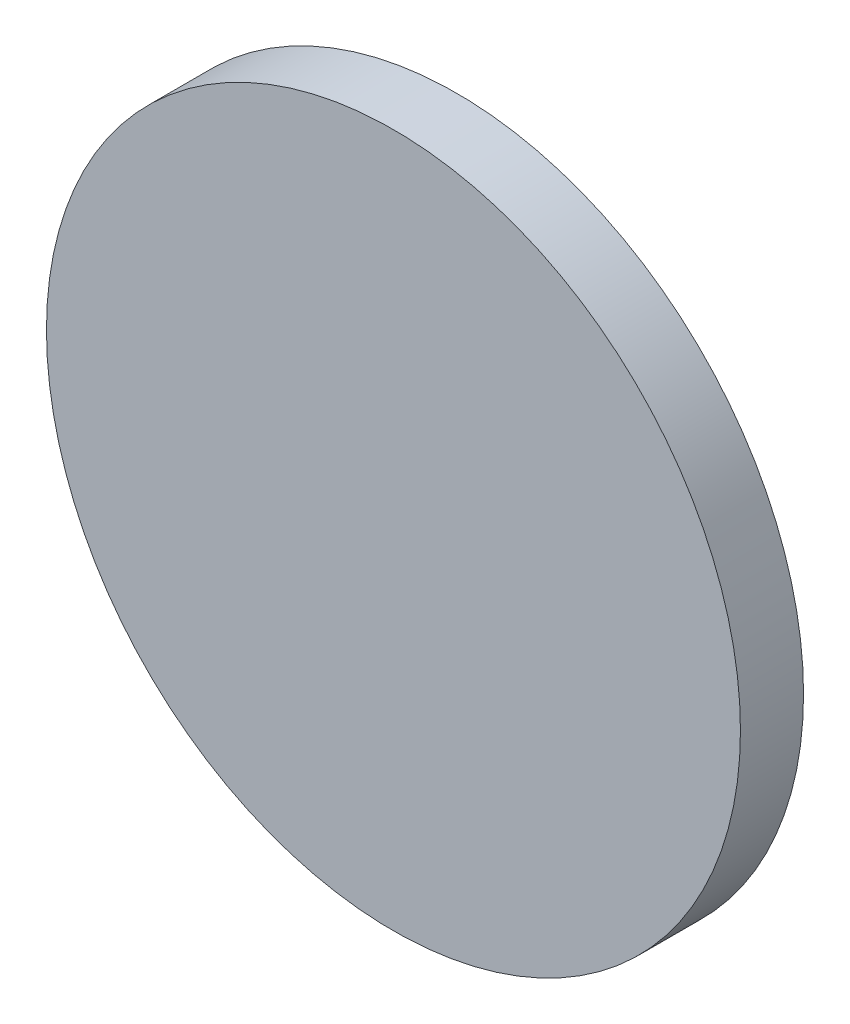
from build123d import *

# Parameters (mm, degrees)
SKETCH1_R           = 11
BOSS_EXTRUDE1_DEPTH = 2


with BuildPart() as part:
    # Sketch1 → Boss-Extrude1 (new body)
    with BuildSketch(Plane.XY):
        Circle(SKETCH1_R)
    extrude(amount=BOSS_EXTRUDE1_DEPTH)


solid = part.part
